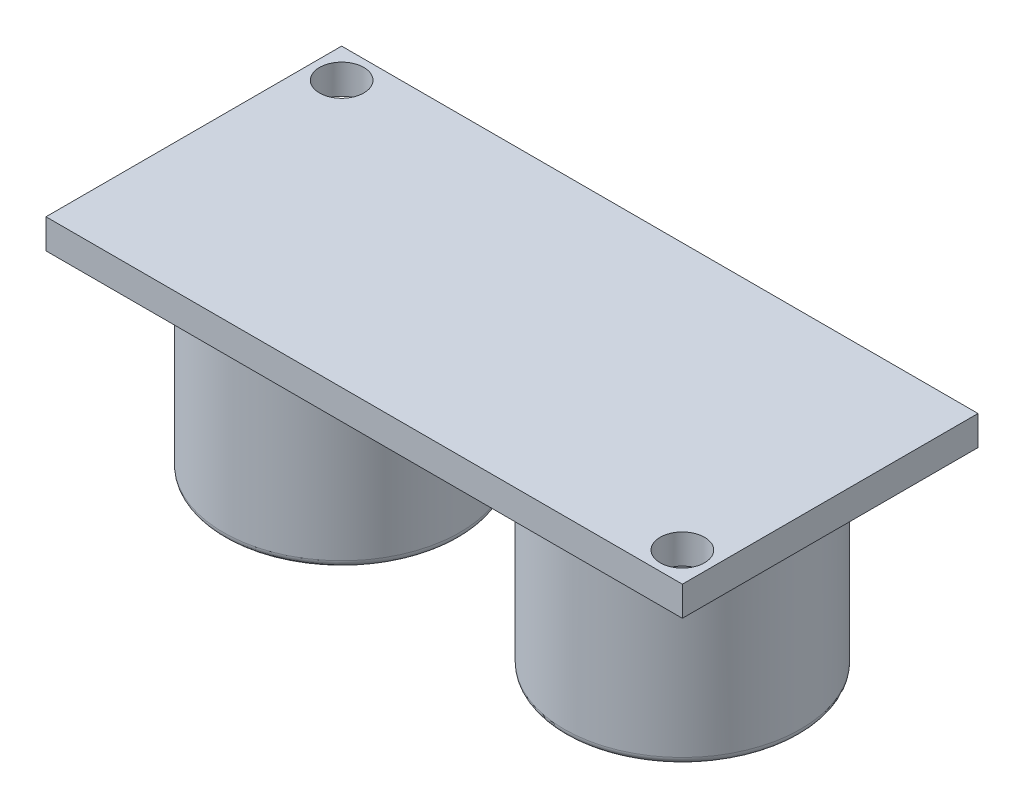
from build123d import *

# Parameters (mm, degrees)
SCHIZZO1_W                   = 43.05
SCHIZZO1_H                   = 20
ESTRUSIONE_ESTRUSIONE1_DEPTH = 2
ESTRUSIONE_ESTRUSIONE2_DEPTH = 2.5
SCHIZZO3_W                   = 8
SCHIZZO3_H                   = 13
SCHIZZO4_W                   = 8
SCHIZZO4_H                   = 13
FORO_3_0_3_1_D               = 3
FORO_3_0_3_1_DEPTH           = 15
RACCORDO1_R                  = 0.5


with BuildPart() as part:
    # Schizzo1 → Estrusione-Estrusione1 (new body)
    with BuildSketch(Plane.XZ.offset(1)):
        Rectangle(SCHIZZO1_W, SCHIZZO1_H)
    extrude(amount=-ESTRUSIONE_ESTRUSIONE1_DEPTH)

    # Schizzo2 → Estrusione-Estrusione2 (add)
    with BuildSketch(Plane.XZ.offset(1)):
        with BuildLine():
            Line((-1.776510899, -8.758979541), (-1.776510899, -5.241020459))
            ThreePointArc((-1.776510899, -5.241020459), (0.01258154, -4.500031659), (1.794125223, -5.258990326))
            Line((1.794125223, -5.258990326), (1.794125223, -8.741009674))
            ThreePointArc((1.794125223, -8.741009674), (0.01258154, -9.499968341), (-1.776510899, -8.758979541))
        make_face()
    extrude(amount=ESTRUSIONE_ESTRUSIONE2_DEPTH)

    # Schizzo3 → Rivoluzione1 (revolve)
    with BuildSketch(Plane(origin=(0, 0, 0), x_dir=(-1, 0, 0), z_dir=(0, 0, -1))):
        with Locations((7.525, -7.5)):
            Rectangle(SCHIZZO3_W, SCHIZZO3_H)
    revolve(axis=Axis((-11.525, -14, 0), (0, 1, 0)))

    # Schizzo4 → Rivoluzione2 (revolve)
    with BuildSketch(Plane(origin=(0, 0, 0), x_dir=(-1, 0, 0), z_dir=(0, 0, -1))):
        with Locations((-15.525, -7.5)):
            Rectangle(SCHIZZO4_W, SCHIZZO4_H)
    revolve(axis=Axis((11.525, -14, 0), (0, 1, 0)))

    # Foro Ø3.0 (3)-1
    with Locations(Plane(origin=(0, 1, 0), x_dir=(1, 0, 0), z_dir=(0, 1, 0))):
        with Locations((-19.525, 8), (19.525, -8)):
            Hole(FORO_3_0_3_1_D / 2, depth=FORO_3_0_3_1_DEPTH)

    # Raccordo1
    raccordo1_edges = [part.edges().sort_by_distance(p)[0] for p in [
        (-19.525, -14, 0),
        (3.525, -14, 0),
    ]]
    fillet(raccordo1_edges, radius=RACCORDO1_R)


solid = part.part
